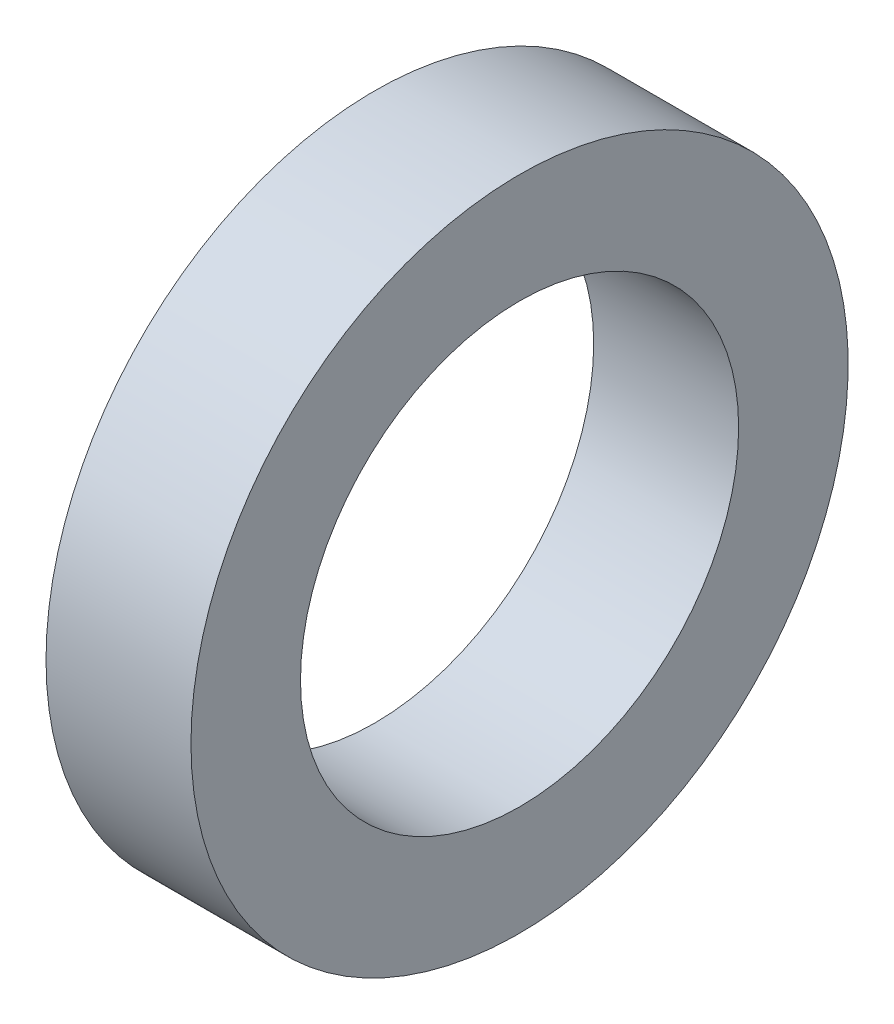
from build123d import *

# Parameters (mm, degrees)
SKETCH3_W = 3.969999934
SKETCH3_H = 3.000000096


with BuildPart() as part:
    # Sketch3 → Revolve1 (revolve)
    with BuildSketch(Plane.XY):
        with Locations((7.994399683, 7.499999986)):
            Rectangle(SKETCH3_W, SKETCH3_H)
    revolve(axis=Axis((0, 0, 0), (1, 0, 0)))


solid = part.part
